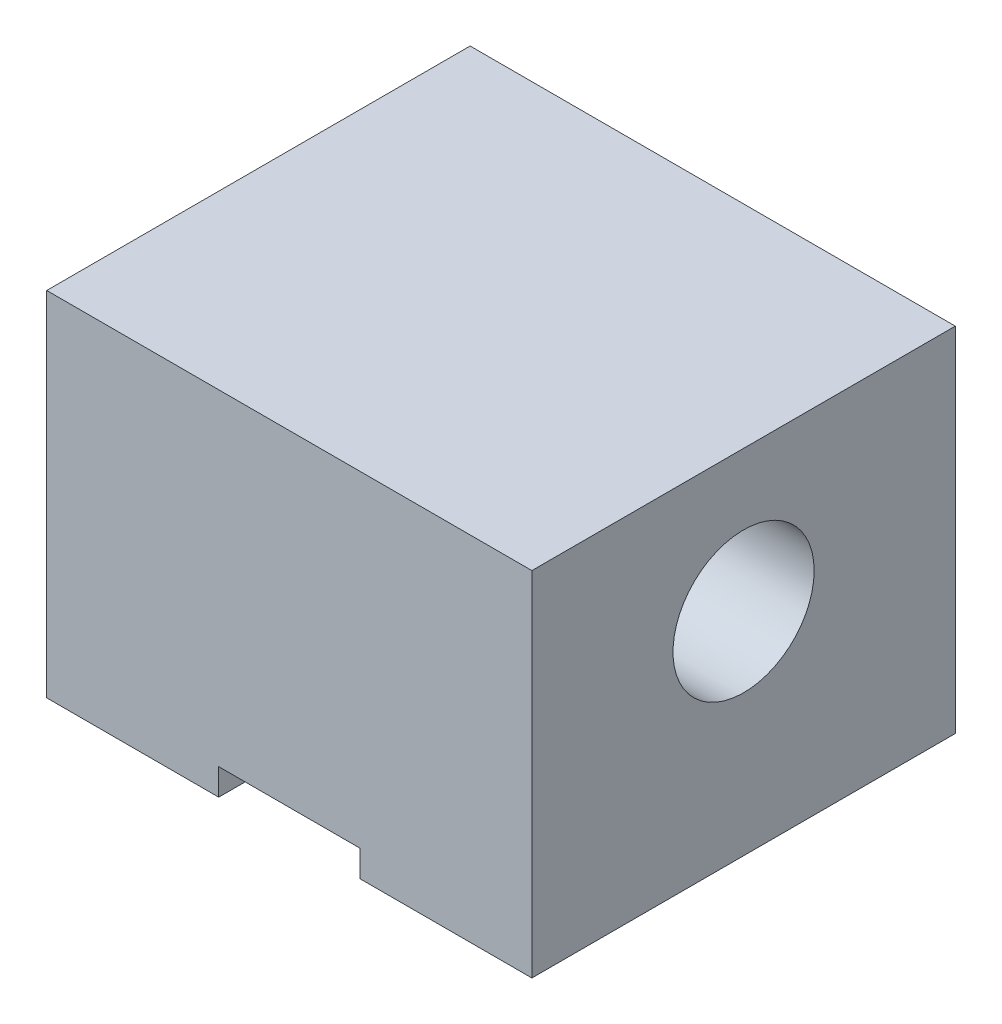
from build123d import *

# Parameters (mm, degrees)
SKETCH1_W           = 87.3125
SKETCH1_H           = 76.2
BOSS_EXTRUDE1_DEPTH = 63.5
SKETCH2_W           = 25.4
SKETCH2_H           = 76.2
CUT_EXTRUDE1_DEPTH  = 4.7625
SKETCH3_R           = 12.7
CUT_EXTRUDE2_DEPTH  = 88.3125


with BuildPart() as part:
    # Sketch1 → Boss-Extrude1 (new body)
    with BuildSketch(Plane(origin=(0, 0, 0), x_dir=(1, 0, 0), z_dir=(0, 1, 0))):
        Rectangle(SKETCH1_W, SKETCH1_H)
    extrude(amount=BOSS_EXTRUDE1_DEPTH)

    # Sketch2 → Cut-Extrude1 (cut)
    with BuildSketch(Plane.XZ):
        Rectangle(SKETCH2_W, SKETCH2_H)
    extrude(amount=-CUT_EXTRUDE1_DEPTH, mode=Mode.SUBTRACT)

    # Sketch3 → Cut-Extrude2 (cut, through all)
    with BuildSketch(Plane(origin=(43.65625, 0, 0), x_dir=(0, 0, -1), z_dir=(1, 0, 0))):
        with Locations((0, 38.1)):
            Circle(SKETCH3_R)
    extrude(amount=-CUT_EXTRUDE2_DEPTH, mode=Mode.SUBTRACT)


solid = part.part
